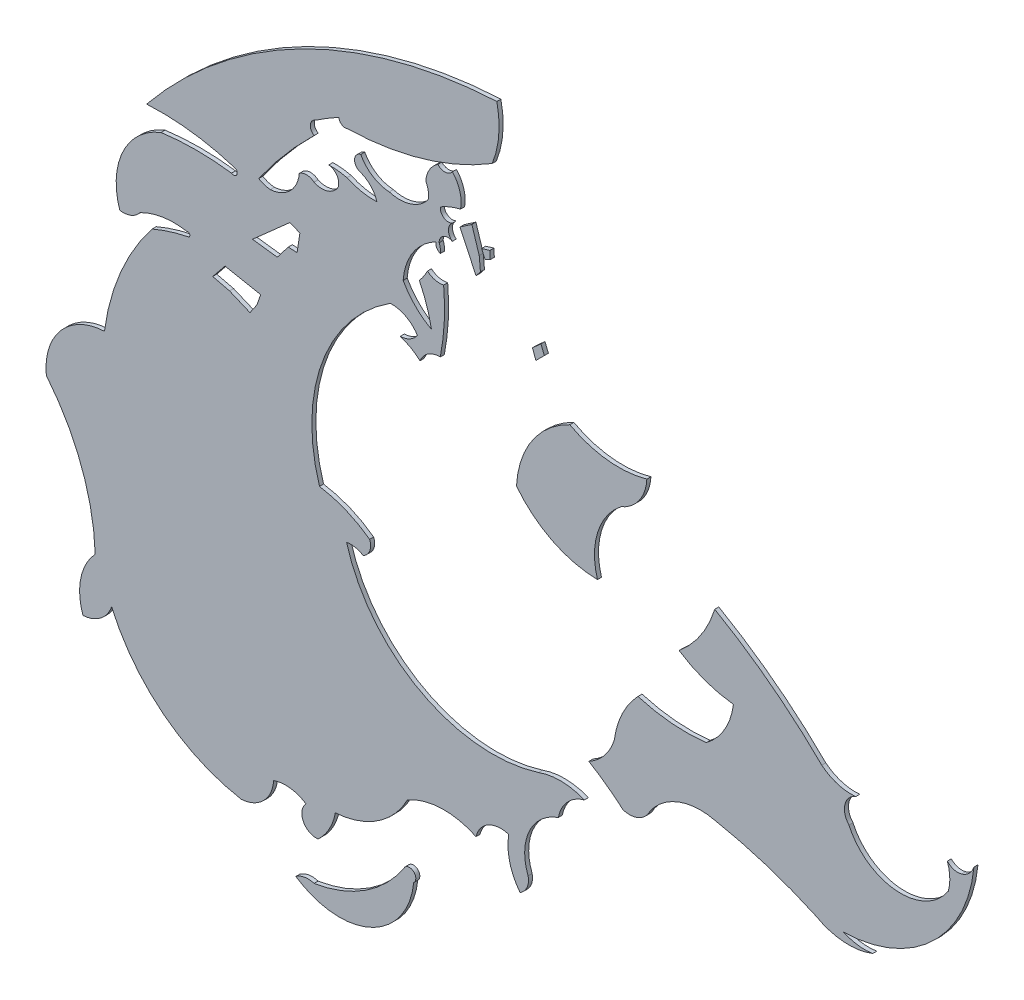
from build123d import *

# Parameters (mm, degrees)
SALIENTE_EXTRUIR1_DEPTH   = 0.1
SALIENTE_EXTRUIR1_2_DEPTH = 0.1
SALIENTE_EXTRUIR1_3_DEPTH = 0.1
SALIENTE_EXTRUIR1_4_DEPTH = 0.1
SALIENTE_EXTRUIR1_5_DEPTH = 0.1
SALIENTE_EXTRUIR1_6_DEPTH = 0.1
SALIENTE_EXTRUIR1_7_DEPTH = 0.1


with BuildPart() as part:
    # Model → Saliente-Extruir1 (new body)
    with BuildSketch(Plane.XY):
        Polygon((62.796765013, 36.946376121), (62.503358934, 36.744027101), (62.9, 35.9), (63.009231483, 36.035805533), (62.97887913, 36.369681415), align=None)
    extrude(amount=SALIENTE_EXTRUIR1_DEPTH)


with BuildPart() as body_2:
    # Model → Saliente-Extruir1 2 (new body)
    with BuildSketch(Plane.XY):
        Polygon((63.039583836, 36.551795532), (63.241932856, 36.612500238), (63.252050307, 36.42026867), (63.120523444, 36.359563964), align=None)
    extrude(amount=SALIENTE_EXTRUIR1_2_DEPTH)


with BuildPart() as body_3:
    # Model → Saliente-Extruir1 3 (new body)
    with BuildSketch(Plane.XY):
        Polygon((64.294163946, 35.056533405), (64.503959409, 35.245349322), (64.587877594, 35.035553859), (64.378082131, 34.825758395), align=None)
    extrude(amount=SALIENTE_EXTRUIR1_3_DEPTH)


with BuildPart() as body_4:
    # Model → Saliente-Extruir1 4 (new body)
    with BuildSketch(Plane.XY):
        with BuildLine():
            ThreePointArc((63.413944704, 39.885560113), (58.622500498, 38.615672334), (54.76409869, 35.503874133))
            ThreePointArc((54.76409869, 35.503874133), (55.876536936, 35.463494222), (56.963107253, 35.221596858))
            ThreePointArc((56.963107253, 35.221596858), (56.984185692, 35.095568653), (56.858157487, 35.074490213))
            ThreePointArc((56.858157487, 35.074490213), (55.989079779, 35.133292241), (55.120002072, 35.074490213))
            ThreePointArc((55.120002072, 35.074490213), (54.175663195, 34.190982744), (54.1, 32.9))
            ThreePointArc((54.1, 32.9), (54.377698396, 32.930754009), (54.6, 33.1))
            ThreePointArc((54.6, 33.1), (55.165310564, 33.284510049), (55.759926524, 33.277309152))
            ThreePointArc((55.759926524, 33.277309152), (55.827478725, 33.246147768), (55.79631734, 33.178595567))
            ThreePointArc((55.79631734, 33.178595567), (55.340844328, 33.062830003), (54.9, 32.9))
            ThreePointArc((54.9, 32.9), (54.122149004, 31.590821761), (53.720158123, 30.122011642))
            ThreePointArc((53.720158123, 30.122011642), (52.644098516, 29.600886303), (52.285157153, 28.460431571))
            ThreePointArc((52.285157153, 28.460431571), (53.154852047, 26.948758897), (53.493579022, 25.237973252))
            ThreePointArc((53.493579022, 25.237973252), (53.136382803, 24.550535416), (53.191473555, 23.777796826))
            ThreePointArc((53.191473555, 23.777796826), (53.626670873, 23.939927075), (53.898400349, 24.316551576))
            ThreePointArc((53.898400349, 24.316551576), (55.183469931, 22.65659841), (57.1, 21.8))
            ThreePointArc((57.1, 21.8), (57.652079729, 22.047920271), (57.9, 22.6))
            ThreePointArc((57.9, 22.6), (58.311803399, 22.644427191), (58.7, 22.5))
            ThreePointArc((58.7, 22.5), (58.633772234, 22.091886117), (59, 21.9))
            ThreePointArc((59, 21.9), (59.274640176, 22.251702899), (59.42471138, 22.671941866))
            ThreePointArc((59.42471138, 22.671941866), (60.470089064, 23.023558326), (61.20797282, 23.843299871))
            ThreePointArc((61.20797282, 23.843299871), (62.047046093, 24.078760657), (62.9, 23.9))
            ThreePointArc((62.9, 23.9), (63.204536006, 24.303664331), (63.708035427, 24.350305574))
            ThreePointArc((63.708035427, 24.350305574), (63.732921789, 23.770391903), (63.987762711, 23.248879391))
            ThreePointArc((63.987762711, 23.248879391), (64.160052621, 23.445312476), (64.186508947, 23.705254456))
            ThreePointArc((64.186508947, 23.705254456), (64.215082295, 24.674739865), (64.933194312, 25.326685817))
            ThreePointArc((64.933194312, 25.326685817), (65.155254559, 25.766575229), (65.575984302, 26.023090203))
            ThreePointArc((65.575984302, 26.023090203), (65.011505662, 26.139912018), (64.443088799, 26.044069749))
            ThreePointArc((64.443088799, 26.044069749), (61.531336835, 26.319561335), (59.7, 28.6))
            ThreePointArc((59.7, 28.6), (59.913845405, 28.597543542), (60.113793753, 28.521671615))
            ThreePointArc((60.113793753, 28.521671615), (60.275313118, 28.703292214), (60.271909601, 28.946320943))
            ThreePointArc((60.271909601, 28.946320943), (59.68382047, 29.278422955), (59.033277184, 29.459900238))
            ThreePointArc((59.033277184, 29.459900238), (59.098731826, 32.150293783), (60.781486531, 34.250493378))
            ThreePointArc((60.781486531, 34.250493378), (61.163534111, 34.165665897), (61.451666484, 33.900834272))
            ThreePointArc((61.451666484, 33.900834272), (61.268906892, 33.732638065), (61.029161731, 33.667728201))
            ThreePointArc((61.029161731, 33.667728201), (61.287488507, 33.553412794), (61.517714837, 33.389716206))
            ThreePointArc((61.517714837, 33.389716206), (61.715234577, 33.633650915), (62.016948705, 33.720177067))
            ThreePointArc((62.016948705, 33.720177067), (62.114758857, 34.507129657), (62.1, 35.3))
            ThreePointArc((62.1, 35.3), (61.888196601, 35.302786405), (61.7, 35.4))
            ThreePointArc((61.7, 35.4), (61.609135943, 35.243909371), (61.5, 35.1))
            ThreePointArc((61.5, 35.1), (61.680540497, 34.660180166), (61.8, 34.2))
            ThreePointArc((61.8, 34.2), (61.4, 34.5), (61.1, 34.9))
            ThreePointArc((61.1, 34.9), (61.346637259, 35.624630493), (61.918000453, 36.134005984))
            ThreePointArc((61.918000453, 36.134005984), (61.926579096, 36.013295305), (62.018000453, 35.934005984))
            ThreePointArc((62.018000453, 35.934005984), (62.016792429, 36.043765114), (61.9888581, 36.149916888))
            ThreePointArc((61.9888581, 36.149916888), (62.094524241, 36.340707325), (62.312616531, 36.342148457))
            ThreePointArc((62.312616531, 36.342148457), (62.218015294, 36.539413979), (62.318000453, 36.734005984))
            ThreePointArc((62.318000453, 36.734005984), (62.106197054, 36.741300885), (62.018000453, 36.934005984))
            ThreePointArc((62.018000453, 36.934005984), (62.260893671, 37.051772937), (62.518000453, 37.134005984))
            ThreePointArc((62.518000453, 37.134005984), (62.500624245, 37.507612781), (62.318000453, 37.834005984))
            ThreePointArc((62.318000453, 37.834005984), (62.143257737, 37.734330436), (61.956677861, 37.809551321))
            ThreePointArc((61.956677861, 37.809551321), (61.747896262, 37.591324336), (61.659467621, 37.302545617))
            ThreePointArc((61.659467621, 37.302545617), (61.71982125, 37.123213187), (61.718000453, 36.934005984))
            ThreePointArc((61.718000453, 36.934005984), (61.285490108, 36.628226677), (60.75584298, 36.621893968))
            ThreePointArc((60.75584298, 36.621893968), (60.345032182, 36.754448319), (60.051668392, 37.071108792))
            ThreePointArc((60.051668392, 37.071108792), (59.899558442, 36.895882127), (60.015245569, 36.694739615))
            ThreePointArc((60.015245569, 36.694739615), (60.288776041, 36.531196205), (60.452319451, 36.257665733))
            ThreePointArc((60.452319451, 36.257665733), (60.073299103, 36.286176367), (59.711722039, 36.403357027))
            ThreePointArc((59.711722039, 36.403357027), (59.488840288, 36.443601267), (59.262507216, 36.451920792))
            ThreePointArc((59.262507216, 36.451920792), (59.466007565, 36.325642233), (59.493185098, 36.087692557))
            ThreePointArc((59.493185098, 36.087692557), (59.232947195, 35.878950758), (58.9, 35.9))
            ThreePointArc((58.9, 35.9), (58.718004977, 35.967051894), (58.534050745, 35.905578439))
            ThreePointArc((58.534050745, 35.905578439), (58.306138548, 35.420999965), (57.817735216, 35.201403851))
            ThreePointArc((57.817735216, 35.201403851), (57.669422237, 35.231421584), (57.532144495, 35.295081817))
            ThreePointArc((57.532144495, 35.295081817), (58.178246942, 36.129779033), (58.9, 36.9))
            ThreePointArc((58.9, 36.9), (58.806518868, 37.084761281), (58.937074782, 37.24548031))
            ThreePointArc((58.937074782, 37.24548031), (59.221681793, 37.426681752), (59.514012306, 37.595139415))
            ThreePointArc((59.514012306, 37.595139415), (59.585518241, 37.469828929), (59.729311663, 37.45802772))
            ThreePointArc((59.729311663, 37.45802772), (61.583505909, 37.743074602), (63.3, 38.5))
            ThreePointArc((63.3, 38.5), (63.46272224, 39.184083472), (63.413944704, 39.885560113))
        make_face()
        Polygon((57.378260636, 33.919566187), (58.304857266, 34.741265086), (58.54961864, 34.636367354), (58.479686819, 34.181810516), (58.262606791, 34.19557025), (57.989435614, 33.841459465), align=None, mode=Mode.SUBTRACT)
        Polygon((56.699588499, 33.006619212), (56.39606497, 32.632273526), (56.81088046, 32.531099016), (57.316753009, 32.318632545), (57.488749675, 32.57156882), (57.579806734, 32.834622545), align=None, mode=Mode.SUBTRACT)
    extrude(amount=SALIENTE_EXTRUIR1_4_DEPTH)


with BuildPart() as body_5:
    # Model → Saliente-Extruir1 5 (new body)
    with BuildSketch(Plane.XY):
        with BuildLine():
            ThreePointArc((65.21660694, 33.871174961), (64.285708084, 33.067662124), (63.9, 31.9))
            ThreePointArc((63.9, 31.9), (64.786330954, 31.172661908), (65.9, 30.9))
            ThreePointArc((65.9, 30.9), (65.904679785, 31.91511651), (66.482093176, 32.750028004))
            ThreePointArc((66.482093176, 32.750028004), (66.933056337, 33.112266522), (67.119871385, 33.659701134))
            ThreePointArc((67.119871385, 33.659701134), (66.147506335, 33.578842597), (65.21660694, 33.871174961))
        make_face()
    extrude(amount=SALIENTE_EXTRUIR1_5_DEPTH)


with BuildPart() as body_6:
    # Model → Saliente-Extruir1 6 (new body)
    with BuildSketch(Plane.XY):
        with BuildLine():
            ThreePointArc((66.9, 28.9), (66.511513024, 28.336098254), (66.316270841, 27.679753985))
            ThreePointArc((66.316270841, 27.679753985), (66.077987679, 27.231421788), (65.688616269, 26.905583592))
            ThreePointArc((65.688616269, 26.905583592), (66.126093275, 26.613206935), (66.538482152, 26.286395592))
            ThreePointArc((66.538482152, 26.286395592), (66.927469809, 26.320369975), (67.2, 26.6))
            ThreePointArc((67.2, 26.6), (67.908008833, 27.145309778), (68.8, 27.2))
            ThreePointArc((68.8, 27.2), (70.074009569, 26.875029904), (71.3, 26.4))
            ThreePointArc((71.3, 26.4), (71.988756689, 26.192593641), (72.7, 26.3))
            ThreePointArc((72.7, 26.3), (72.33265743, 26.29515884), (71.97970818, 26.397094246))
            ThreePointArc((71.97970818, 26.397094246), (74.159973939, 27.287155212), (75.2, 29.4))
            ThreePointArc((75.2, 29.4), (75.086511455, 29.213488545), (74.9, 29.1))
            ThreePointArc((74.9, 29.1), (74.706935797, 29.098025025), (74.541791511, 29.198050282))
            ThreePointArc((74.541791511, 29.198050282), (74.603367003, 28.884103154), (74.566267648, 28.56633283))
            ThreePointArc((74.566267648, 28.56633283), (73.283226533, 27.936151291), (72.111660725, 28.755148748))
            ThreePointArc((72.111660725, 28.755148748), (72.01235602, 29.145728933), (72.279497096, 29.447473777))
            ThreePointArc((72.279497096, 29.447473777), (71.835172681, 29.490906096), (71.440315242, 29.699228333))
            ThreePointArc((71.440315242, 29.699228333), (70.1841707, 30.792303086), (68.796892402, 31.713264783))
            ThreePointArc((68.796892402, 31.713264783), (68.453714712, 30.987480551), (67.915751455, 30.391553363))
            ThreePointArc((67.915751455, 30.391553363), (68.55803683, 30.06942567), (69.258442422, 29.909023797))
            ThreePointArc((69.258442422, 29.909023797), (69.040960618, 29.263320636), (68.587096938, 28.755148748))
            ThreePointArc((68.587096938, 28.755148748), (67.736144446, 28.741338977), (66.9, 28.9))
        make_face()
    extrude(amount=SALIENTE_EXTRUIR1_6_DEPTH)


with BuildPart() as body_7:
    # Model → Saliente-Extruir1 7 (new body)
    with BuildSketch(Plane.XY):
        with BuildLine():
            ThreePointArc((58.9, 20.9), (60.184225961, 21.397472492), (61.149487439, 22.379809236))
            ThreePointArc((61.149487439, 22.379809236), (61.371539749, 22.368715589), (61.360446102, 22.146663278))
            ThreePointArc((61.360446102, 22.146663278), (60.663050963, 20.880232868), (59.266133749, 20.50763622))
            ThreePointArc((59.266133749, 20.50763622), (58.839479851, 20.620306135), (58.44662022, 20.8212772))
            ThreePointArc((58.44662022, 20.8212772), (58.66379873, 20.915416474), (58.9, 20.9))
        make_face()
    extrude(amount=SALIENTE_EXTRUIR1_7_DEPTH)


solid = Compound([part.part, body_2.part, body_3.part, body_4.part, body_5.part, body_6.part, body_7.part])
